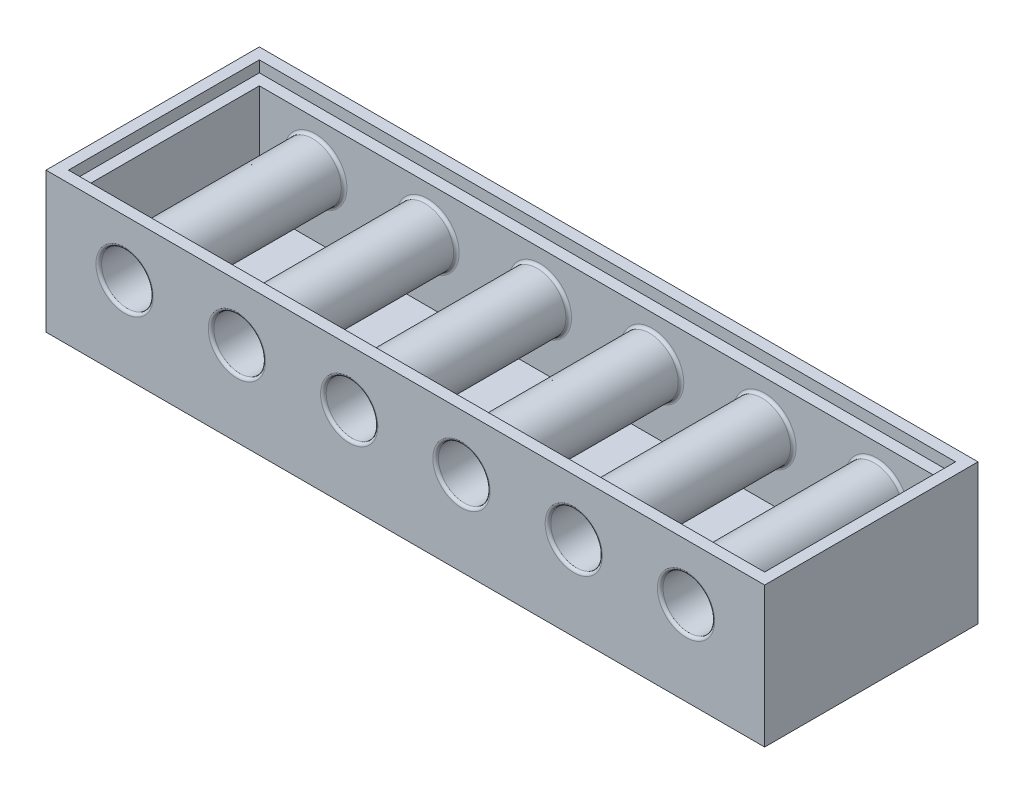
from build123d import *

# Parameters (mm, degrees)
SKETCH1_W               = 160
SKETCH1_H               = 30
BOSS_EXTRUDE1_DEPTH     = 4
SKETCH2_W               = 168
SKETCH2_H               = 38
SKETCH2_W_2             = 160
SKETCH2_H_2             = 30
EXTRUDE_THIN1_DEPTH     = 65
SKETCH4_R               = 4.6
CUT_EXTRUDE1_DEPTH      = 38
EXTRUDE_THIN3_START     = -34
SKETCH5_R               = 5.1
SKETCH5_R_2             = 4.6
EXTRUDE_THIN3_DEPTH     = 30
LPATTERN1_COUNT         = 3
LPATTERN1_PITCH         = 20
BOSS_EXTRUDE2_REACH     = 40
SKETCH7_W               = 4
SKETCH7_H               = 65
CUT_EXTRUDE2_DEPTH      = 1
CUT_EXTRUDE2_DEPTH_BACK = 39
CUT_EXTRUDE3_DEPTH      = 1
CUT_EXTRUDE3_DEPTH_BACK = 39
SKETCH11_W              = 124
SKETCH11_H              = 34
CUT_EXTRUDE4_DEPTH      = 2
FILLET1_R               = 0.5


with BuildPart() as part:
    # Sketch1 → Boss-Extrude1 (new body)
    with BuildSketch(Plane(origin=(0, 0, 0), x_dir=(1, 0, 0), z_dir=(0, 1, 0))):
        Rectangle(SKETCH1_W, SKETCH1_H)
    extrude(amount=BOSS_EXTRUDE1_DEPTH)

    # Sketch2 → Extrude-Thin1 (add)
    with BuildSketch(Plane(origin=(0, 0, 0), x_dir=(1, 0, 0), z_dir=(0, 1, 0))):
        Rectangle(SKETCH2_W, SKETCH2_H)
        Rectangle(SKETCH2_W_2, SKETCH2_H_2, mode=Mode.SUBTRACT)
    extrude(amount=EXTRUDE_THIN1_DEPTH)

    # Sketch4 → Cut-Extrude1 (cut)
    with BuildSketch(Plane.XY.offset(19)):
        with Locations((-70, 55)):
            Circle(SKETCH4_R)
        with Locations((-50, 55)):
            Circle(SKETCH4_R)
        with Locations((-30, 55)):
            Circle(SKETCH4_R)
        with Locations((-10, 55)):
            Circle(SKETCH4_R)
        with Locations((10, 55)):
            Circle(SKETCH4_R)
        with Locations((30, 55)):
            Circle(SKETCH4_R)
        with Locations((50, 55)):
            Circle(SKETCH4_R)
        with Locations((70, 55)):
            Circle(SKETCH4_R)
    cut_extrude1 = extrude(amount=-CUT_EXTRUDE1_DEPTH, mode=Mode.SUBTRACT)

    # Sketch5 → Extrude-Thin3 (add)
    with BuildSketch(Plane.XY.offset(19).offset(EXTRUDE_THIN3_START)):
        with Locations((-30, 55)):
            Circle(SKETCH5_R)
        with Locations((-30, 55)):
            Circle(SKETCH5_R_2, mode=Mode.SUBTRACT)
        with Locations((-50, 55)):
            Circle(SKETCH5_R)
        with Locations((-50, 55)):
            Circle(SKETCH5_R_2, mode=Mode.SUBTRACT)
        with Locations((70, 55)):
            Circle(SKETCH5_R)
        with Locations((70, 55)):
            Circle(SKETCH5_R_2, mode=Mode.SUBTRACT)
        with Locations((50, 55)):
            Circle(SKETCH5_R)
        with Locations((50, 55)):
            Circle(SKETCH5_R_2, mode=Mode.SUBTRACT)
        with Locations((30, 55)):
            Circle(SKETCH5_R)
        with Locations((30, 55)):
            Circle(SKETCH5_R_2, mode=Mode.SUBTRACT)
        with Locations((10, 55)):
            Circle(SKETCH5_R)
        with Locations((10, 55)):
            Circle(SKETCH5_R_2, mode=Mode.SUBTRACT)
        with Locations((-10, 55)):
            Circle(SKETCH5_R)
        with Locations((-10, 55)):
            Circle(SKETCH5_R_2, mode=Mode.SUBTRACT)
        with Locations((-70, 55)):
            Circle(SKETCH5_R)
        with Locations((-70, 55)):
            Circle(SKETCH5_R_2, mode=Mode.SUBTRACT)
    extrude_thin3 = extrude(amount=EXTRUDE_THIN3_DEPTH)

    # LPattern1: Cut-Extrude1, Extrude-Thin3 ×3
    with Locations(*[(0, -i * LPATTERN1_PITCH, 0) for i in range(1, LPATTERN1_COUNT)]):
        add(cut_extrude1, mode=Mode.SUBTRACT)
        add(extrude_thin3)

    # Sketch7 → Boss-Extrude2 (add, up to next)
    with BuildSketch(Plane.XY.offset(19), mode=Mode.PRIVATE) as boss_extrude2_sk1:
        with Locations((42, 32.5)):
            Rectangle(SKETCH7_W, SKETCH7_H)
    boss_extrude2_tool1 = extrude(boss_extrude2_sk1.sketch, amount=-BOSS_EXTRUDE2_REACH, mode=Mode.PRIVATE) - part.part
    add(boss_extrude2_tool1.solids().sort_by_distance((42, 32.5, 19))[0])

    # Sketch9 → Cut-Extrude2 (cut, two sides)
    with BuildSketch(Plane.XY.offset(19)) as cut_extrude2_sk:
        Polygon((44, 362.116701012), (44, 65), (44, 0), (44, -297.116701012), (638.233402024, -297.116701012), (638.233402024, 362.116701012), align=None)
    extrude(amount=CUT_EXTRUDE2_DEPTH, mode=Mode.SUBTRACT)
    extrude(cut_extrude2_sk.sketch, amount=-CUT_EXTRUDE2_DEPTH_BACK, mode=Mode.SUBTRACT)

    # Sketch10 → Cut-Extrude3 (cut, two sides)
    with BuildSketch(Plane.XY.offset(19)) as cut_extrude3_sk:
        Polygon((-362.208873828, 25), (-84, 25), (44, 25), (322.208873828, 25), (322.208873828, 581.417747656), (-362.208873828, 581.417747656), align=None)
    extrude(amount=CUT_EXTRUDE3_DEPTH, mode=Mode.SUBTRACT)
    extrude(cut_extrude3_sk.sketch, amount=-CUT_EXTRUDE3_DEPTH_BACK, mode=Mode.SUBTRACT)

    # Sketch11 → Cut-Extrude4 (cut)
    with BuildSketch(Plane(origin=(0, 25, 0), x_dir=(1, 0, 0), z_dir=(0, 1, 0))):
        with Locations((-20, 0)):
            Rectangle(SKETCH11_W, SKETCH11_H)
    extrude(amount=-CUT_EXTRUDE4_DEPTH, mode=Mode.SUBTRACT)

    # Fillet1
    fillet1_edges = [part.edges().sort_by_distance(p)[0] for p in [
        (-54.6, 15, 19),
        (-54.6, 15, -19),
        (-34.6, 15, 19),
        (-34.6, 15, -19),
        (-74.6, 15, 19),
        (-74.6, 15, -19),
        (-14.6, 15, 19),
        (-14.6, 15, -19),
        (5.4, 15, 19),
        (5.4, 15, -19),
        (25.4, 15, 19),
        (25.4, 15, -19),
        (-35.1, 15, -15),
        (-35.1, 15, 15),
        (-55.1, 15, -15),
        (-55.1, 15, 15),
        (24.9, 15, -15),
        (24.9, 15, 15),
        (4.9, 15, -15),
        (4.9, 15, 15),
        (-15.1, 15, -15),
        (-15.1, 15, 15),
        (-75.1, 15, -15),
        (-75.1, 15, 15),
    ]]
    fillet(fillet1_edges, radius=FILLET1_R)


solid = part.part
